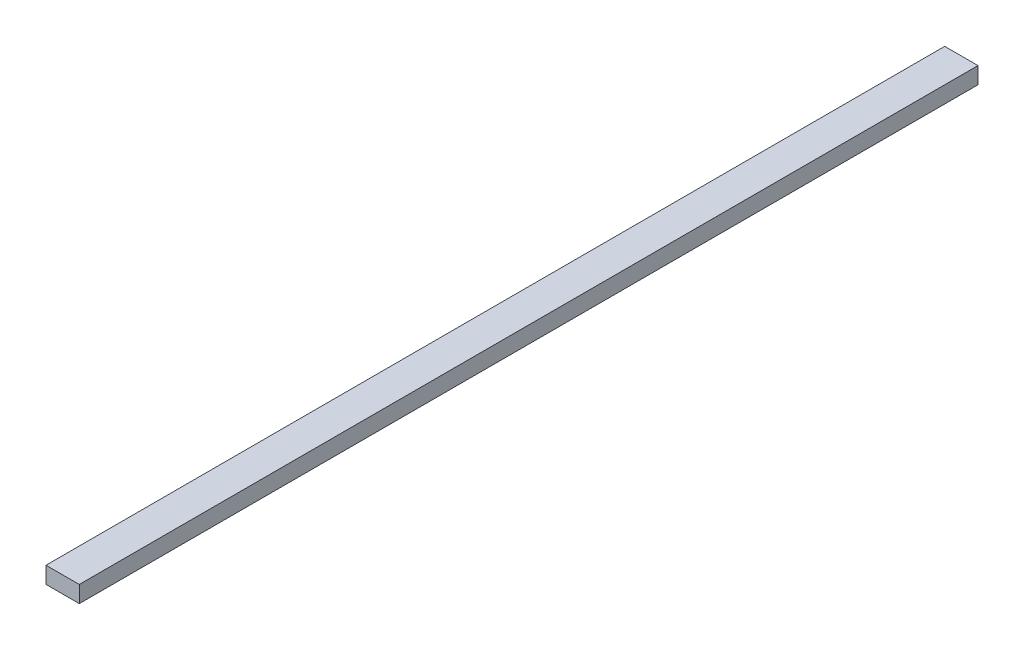
from build123d import *

# Parameters (mm, degrees)
SKETCH1_W           = 101.6
SKETCH1_H           = 50.8
BOSS_EXTRUDE1_DEPTH = 2743.2


with BuildPart() as part:
    # Sketch1 → Boss-Extrude1 (new body)
    with BuildSketch(Plane.XY):
        with Locations((50.8, 25.4)):
            Rectangle(SKETCH1_W, SKETCH1_H)
    extrude(amount=BOSS_EXTRUDE1_DEPTH)


solid = part.part
